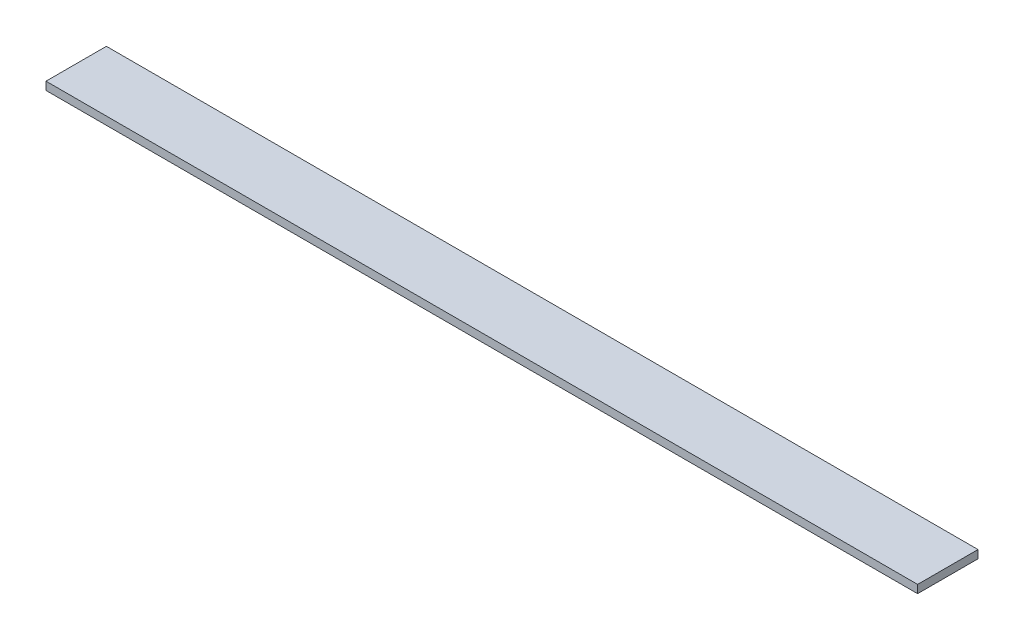
from build123d import *

# Parameters (mm, degrees)
SKETCH_1_W      = 30
SKETCH_1_H      = 4
EXTRUDE_1_DEPTH = 433


with BuildPart() as part:
    # Эскиз1 → Бобышка-Вытянуть1 (new body)
    with BuildSketch(Plane(origin=(0, 0, 0), x_dir=(0, 0, -1), z_dir=(1, 0, 0))):
        Rectangle(SKETCH_1_W, SKETCH_1_H)
    extrude(amount=EXTRUDE_1_DEPTH)


solid = part.part
